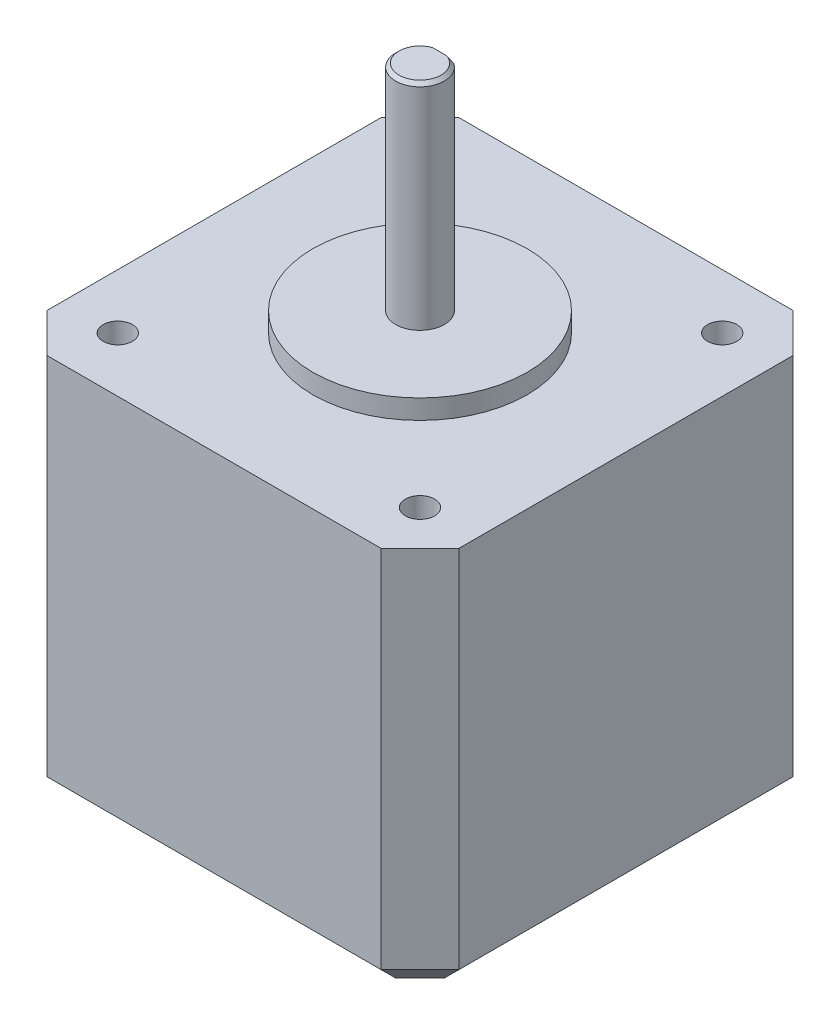
from build123d import *

# Parameters (mm, degrees)
BOSS_EXTRUDE1_DEPTH = 40
SKETCH2_R           = 1.5
CUT_EXTRUDE1_DEPTH  = 5
CHAMFER1_SIZE       = 0.35
D_SHAFT_DEPTH       = 22
CHAMFER2_SIZE       = 2.54


with BuildPart() as part:
    # Sketch1 → Boss-Extrude1 (new body)
    with BuildSketch(Plane(origin=(0, 0, 0), x_dir=(1, 0, 0), z_dir=(0, 1, 0))):
        Polygon((4, 42.3), (0, 38.3), (0, 4), (4, 0), (38.3, 0), (42.3, 4), (42.3, 38.3), (38.3, 42.3), align=None)
    extrude(amount=BOSS_EXTRUDE1_DEPTH)

    # Sketch2 → Cut-Extrude1 (cut)
    with BuildSketch(Plane.XZ.offset(-40)):
        with Locations((5.635, -5.635)):
            Circle(SKETCH2_R)
        with Locations((36.665, -5.635)):
            Circle(SKETCH2_R)
        with Locations((36.665, -36.665)):
            Circle(SKETCH2_R)
        with Locations((5.635, -36.665)):
            Circle(SKETCH2_R)
    extrude(amount=CUT_EXTRUDE1_DEPTH, mode=Mode.SUBTRACT)

    # Sketch6 → Revolve1 (revolve)
    with BuildSketch(Plane.XY.offset(-21.15)):
        Polygon((21.15, 40), (32.15, 40), (32.15, 42), (23.65, 42), (23.65, 64), (21.15, 64), align=None)
    revolve(axis=Axis((21.15, 64, -21.15), (0, -1, 0)))

    # Chamfer1
    chamfer1_edges = [part.edges().sort_by_distance(p)[0] for p in [
        (18.65, 64, -21.15),
    ]]
    chamfer(chamfer1_edges, length=CHAMFER1_SIZE)

    # Sketch7 → D shaft (cut)
    with BuildSketch(Plane(origin=(0, 64, 0), x_dir=(1, 0, 0), z_dir=(0, 1, 0))):
        with BuildLine():
            Line((22.621309131, 23.1712), (19.678690869, 23.1712))
            ThreePointArc((19.678690869, 23.1712), (21.15, 23.65), (22.621309131, 23.1712))
        make_face()
    extrude(amount=-D_SHAFT_DEPTH, mode=Mode.SUBTRACT)

    # Chamfer2
    chamfer2_edges = [part.edges().sort_by_distance(p)[0] for p in [
        (2, 0, -40.3),
        (21.15, 0, -42.3),
        (40.3, 0, -40.3),
        (42.3, 0, -21.15),
        (40.3, 0, -2),
        (21.15, 0, 0),
        (2, 0, -2),
        (0, 0, -21.15),
    ]]
    chamfer(chamfer2_edges, length=CHAMFER2_SIZE)


solid = part.part
